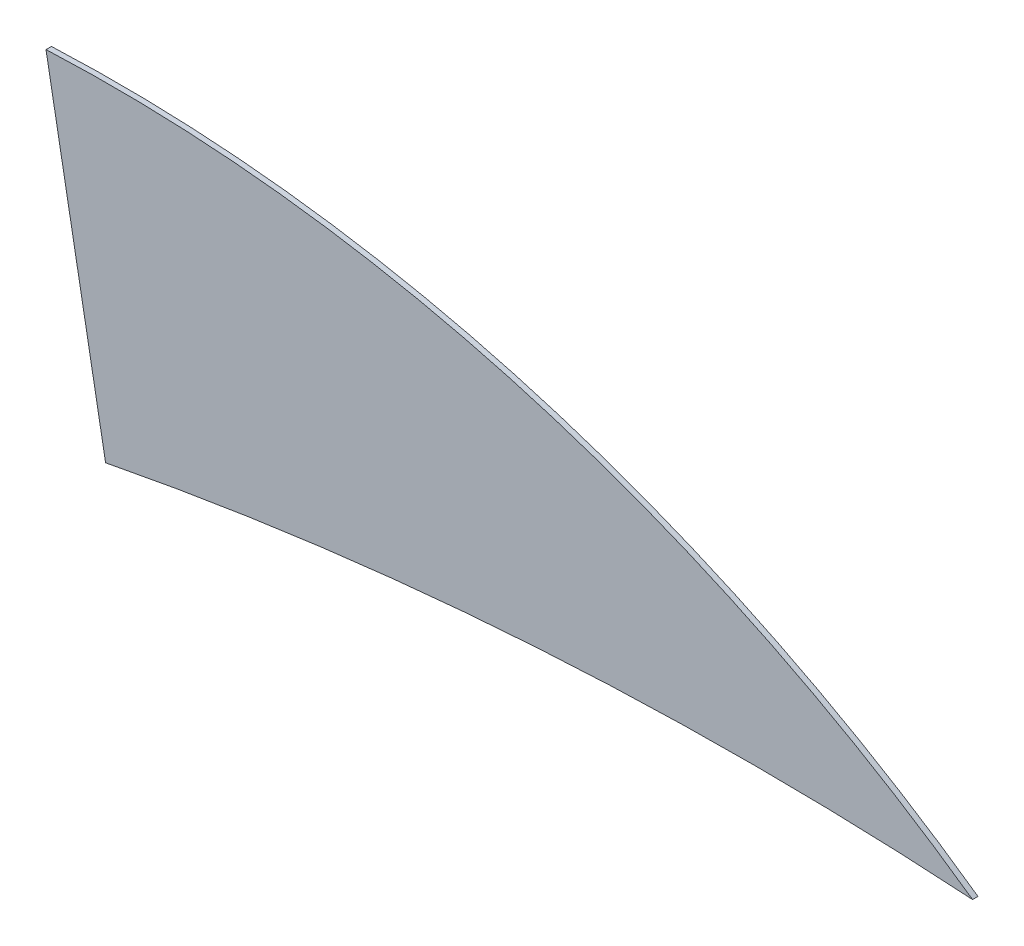
from build123d import *

# Parameters (mm, degrees)
SALIENTE_EXTRUIR1_DEPTH = 0.1


with BuildPart() as part:
    # Model → Saliente-Extruir1 (new body)
    with BuildSketch(Plane.XY):
        with BuildLine():
            Line((21.450133328, 16.558952943), (20.350398635, 22.613714014))
            ThreePointArc((20.350398635, 22.613714014), (29.321362505, 21.524180975), (37.451185299, 17.578137853))
            ThreePointArc((37.451185299, 17.578137853), (29.417774486, 17.584832308), (21.450133328, 16.558952943))
        make_face()
    extrude(amount=SALIENTE_EXTRUIR1_DEPTH)


solid = part.part
